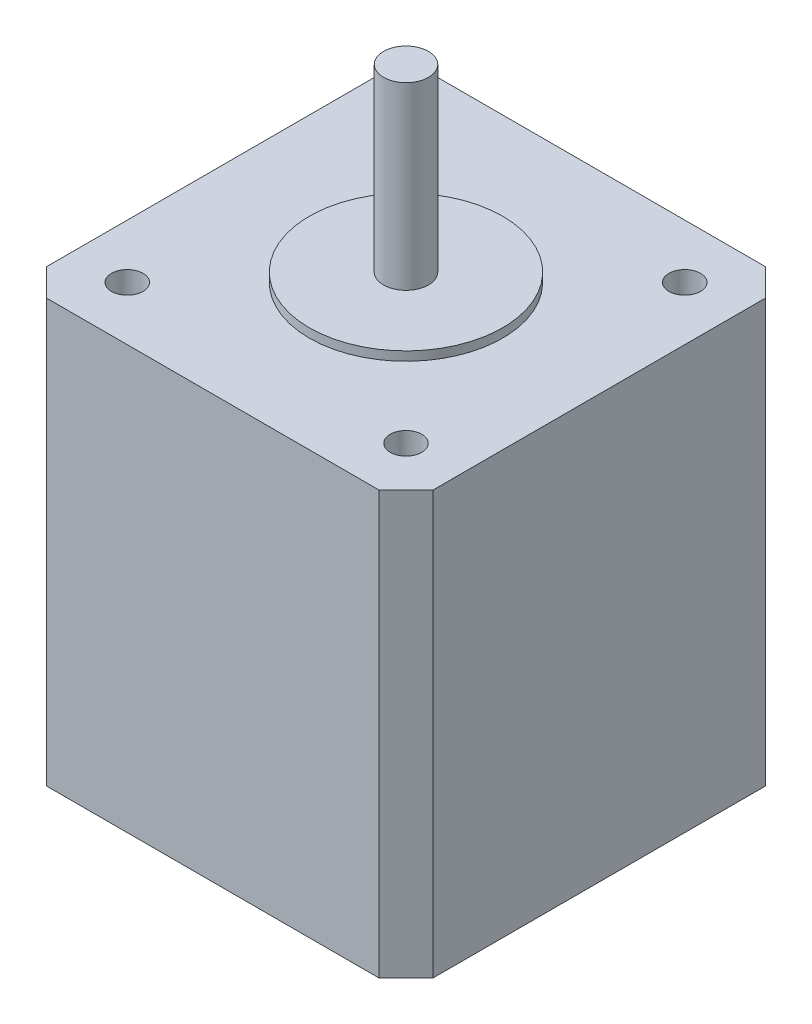
from build123d import *

# Parameters (mm, degrees)
SKETCH1_W           = 43
SKETCH1_H           = 43
BOSS_EXTRUDE1_DEPTH = 47
SKETCH2_R           = 10.75
BOSS_EXTRUDE2_DEPTH = 1
SKETCH3_R           = 2.5
BOSS_EXTRUDE3_DEPTH = 20
CHAMFER1_SIZE       = 3
SKETCH4_R           = 1.75
CUT_EXTRUDE2_DEPTH  = 10


with BuildPart() as part:
    # Sketch1 → Boss-Extrude1 (new body)
    with BuildSketch(Plane(origin=(0, 0, 0), x_dir=(1, 0, 0), z_dir=(0, 1, 0))):
        with Locations((21.5, 21.5)):
            Rectangle(SKETCH1_W, SKETCH1_H)
    extrude(amount=BOSS_EXTRUDE1_DEPTH)

    # Sketch2 → Boss-Extrude2 (add)
    with BuildSketch(Plane(origin=(0, 47, 0), x_dir=(1, 0, 0), z_dir=(0, 1, 0))):
        with Locations((21.5, 21.5)):
            Circle(SKETCH2_R)
    extrude(amount=BOSS_EXTRUDE2_DEPTH)

    # Sketch3 → Boss-Extrude3 (add)
    with BuildSketch(Plane(origin=(0, 48, 0), x_dir=(1, 0, 0), z_dir=(0, 1, 0))):
        with Locations((21.5, 21.5)):
            Circle(SKETCH3_R)
    extrude(amount=BOSS_EXTRUDE3_DEPTH)

    # Chamfer1
    chamfer1_edges = [part.edges().sort_by_distance(p)[0] for p in [
        (0, 23.5, -43),
        (43, 23.5, -43),
        (43, 23.5, 0),
        (0, 23.5, 0),
    ]]
    chamfer(chamfer1_edges, length=CHAMFER1_SIZE)

    # Sketch4 → Cut-Extrude2 (cut)
    with BuildSketch(Plane(origin=(0, 47, 0), x_dir=(1, 0, 0), z_dir=(0, 1, 0))):
        with Locations((6, 37)):
            Circle(SKETCH4_R)
        with Locations((6, 6)):
            Circle(SKETCH4_R)
        with Locations((37, 6)):
            Circle(SKETCH4_R)
        with Locations((37, 37)):
            Circle(SKETCH4_R)
    extrude(amount=-CUT_EXTRUDE2_DEPTH, mode=Mode.SUBTRACT)


solid = part.part
